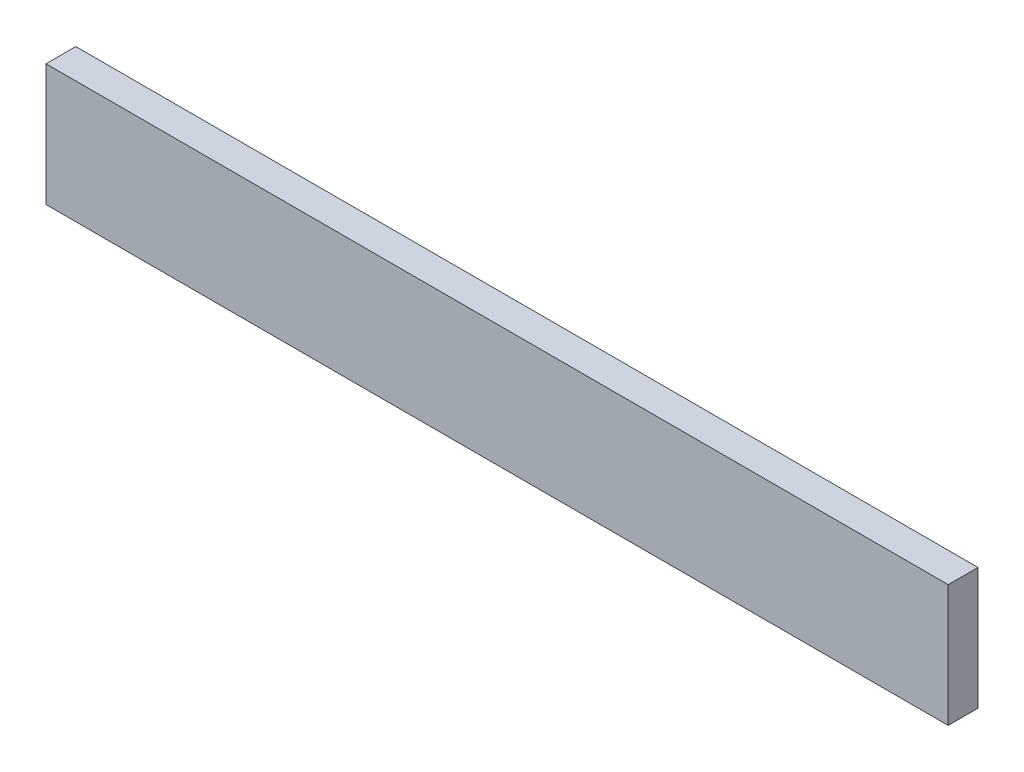
from build123d import *

# Parameters (mm, degrees)
ESQUISSE1_W      = 666
ESQUISSE1_H      = 90
EXTRUSION1_DEPTH = 22


with BuildPart() as part:
    # Esquisse1 → Extrusion1 (new body)
    with BuildSketch(Plane.XY):
        with Locations((333, 45)):
            Rectangle(ESQUISSE1_W, ESQUISSE1_H)
    extrude(amount=EXTRUSION1_DEPTH)


solid = part.part
